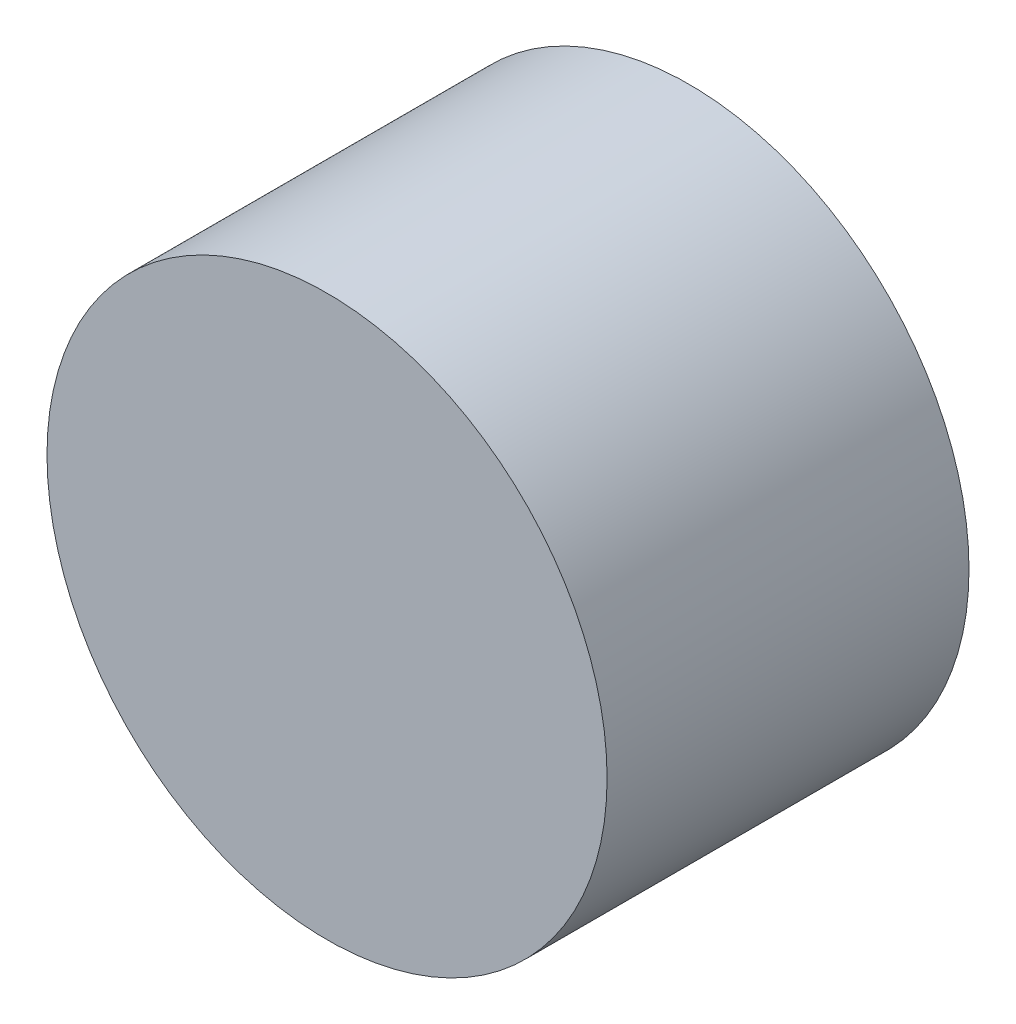
from build123d import *

# Parameters (mm, degrees)
SKETCH1_R           = 32.5
BOSS_EXTRUDE1_DEPTH = 42


with BuildPart() as part:
    # Sketch1 → Boss-Extrude1 (new body)
    with BuildSketch(Plane.XY):
        Circle(SKETCH1_R)
    extrude(amount=BOSS_EXTRUDE1_DEPTH)


solid = part.part
